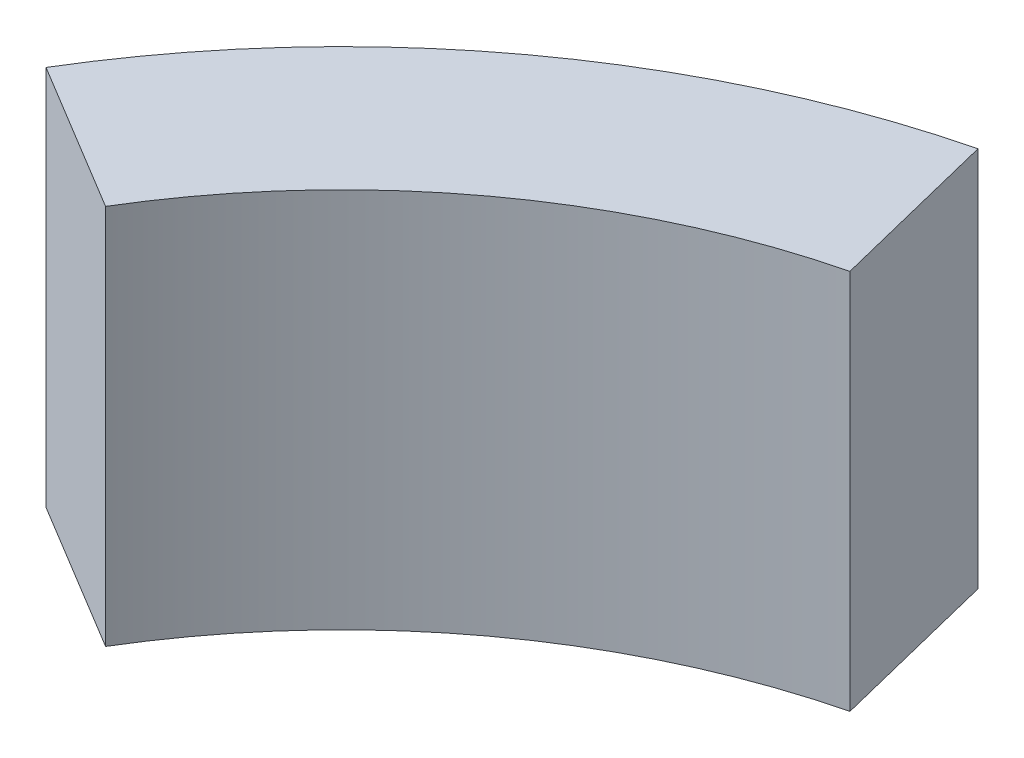
from build123d import *

# Parameters (mm, degrees)
BOSS_EXTRUDE1_DEPTH = 12


with BuildPart() as part:
    # Sketch1 → Boss-Extrude1 (new body)
    with BuildSketch(Plane(origin=(0, 0, 0), x_dir=(1, 0, 0), z_dir=(0, 1, 0))):
        with BuildLine():
            Line((-23.480268416, 14.160981432), (-18.753387247, 11.310193048))
            ThreePointArc((-18.753387247, 11.310193048), (-12.997647146, 17.625866466), (-5.263133092, 21.258161493))
            Line((-5.263133092, 21.258161493), (-6.589731022, 26.61638302))
            ThreePointArc((-6.589731022, 26.61638302), (-16.273766427, 22.068550616), (-23.480268416, 14.160981432))
        make_face()
    extrude(amount=BOSS_EXTRUDE1_DEPTH)


solid = part.part
